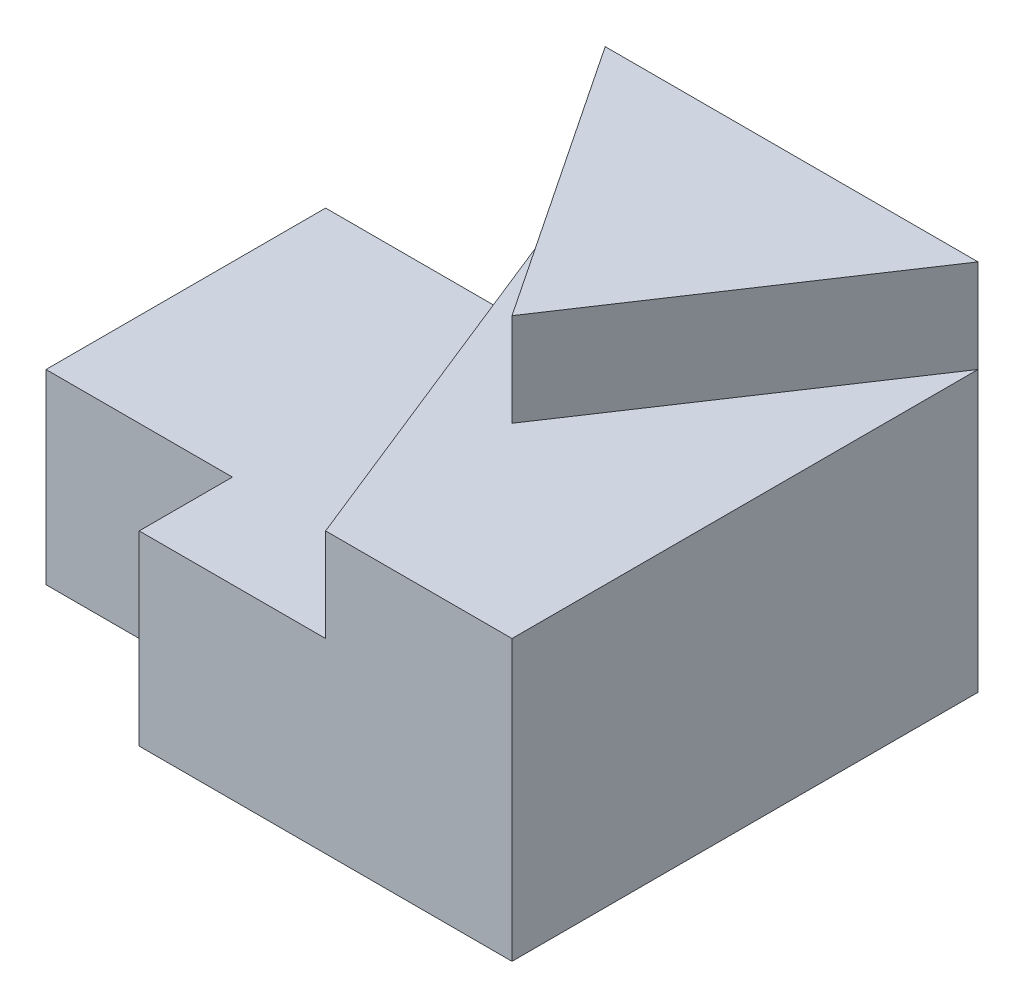
from build123d import *

# Parameters (mm, degrees)
BOSS_EXTRUDE1_DEPTH = 25
SKETCH2_W           = 15
SKETCH2_H           = 10
BOSS_EXTRUDE2_DEPTH = 10
SKETCH3_W           = 25
SKETCH3_H           = 10
BOSS_EXTRUDE3_DEPTH = 10
CUT_EXTRUDE1_DEPTH  = 5
CUT_EXTRUDE2_DEPTH  = 5


with BuildPart() as part:
    # Sketch1 → Boss-Extrude1 (new body)
    with BuildSketch(Plane.XY):
        Polygon((0, 0), (20, 0), (20, 20), (10, 20), (10, 10), (0, 10), align=None)
    extrude(amount=BOSS_EXTRUDE1_DEPTH)

    # Sketch2 → Boss-Extrude2 (add)
    with BuildSketch(Plane.ZY):
        with Locations((12.5, 5)):
            Rectangle(SKETCH2_W, SKETCH2_H)
    extrude(amount=BOSS_EXTRUDE2_DEPTH)

    # Sketch3 → Boss-Extrude3 (add)
    with BuildSketch(Plane.ZY.offset(-10)):
        with Locations((12.5, 15)):
            Rectangle(SKETCH3_W, SKETCH3_H)
    extrude(amount=BOSS_EXTRUDE3_DEPTH)

    # Sketch5 → Cut-Extrude1 (cut)
    with BuildSketch(Plane(origin=(0, 20, 0), x_dir=(1, 0, 0), z_dir=(0, 1, 0))):
        Polygon((0, 0), (0, -25), (20, -25), (20, 0), (10, -15), align=None)
    extrude(amount=-CUT_EXTRUDE1_DEPTH, mode=Mode.SUBTRACT)

    # Sketch6 → Cut-Extrude2 (cut)
    with BuildSketch(Plane(origin=(0, 15, 0), x_dir=(1, 0, 0), z_dir=(0, 1, 0))):
        Polygon((0, -25), (10, -25), (0, 0), align=None)
    extrude(amount=-CUT_EXTRUDE2_DEPTH, mode=Mode.SUBTRACT)


solid = part.part
